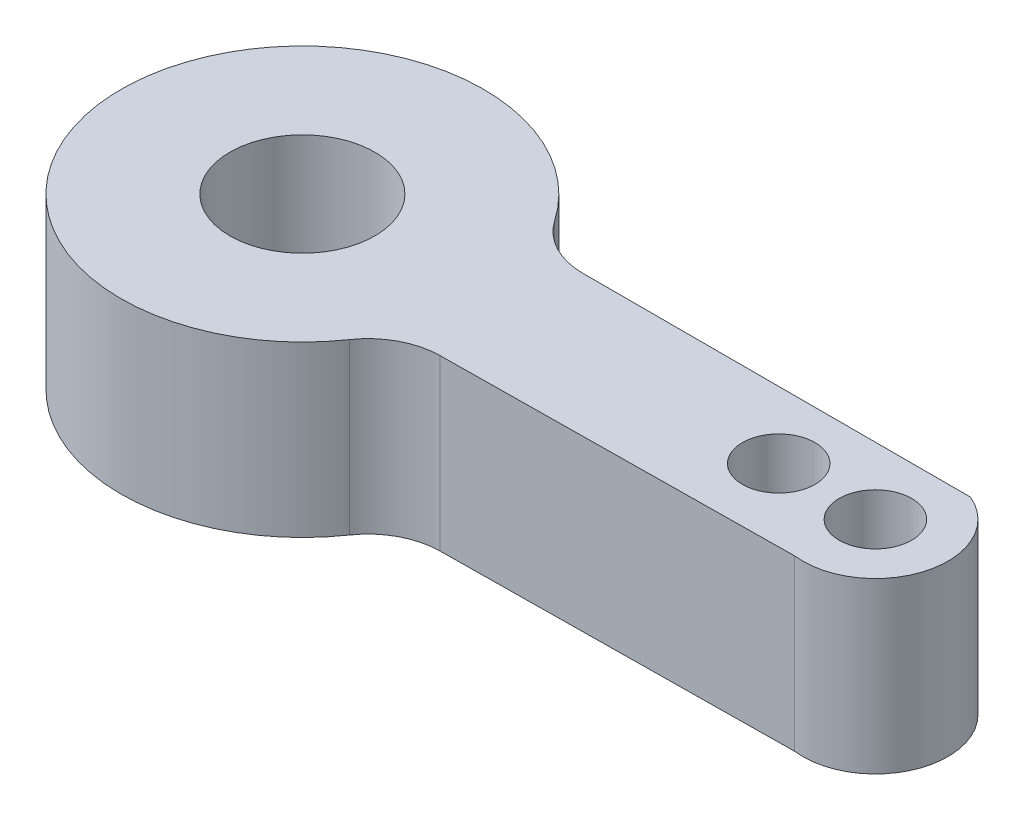
from build123d import *

# Parameters (mm, degrees)
SKETCH4_R           = 1.5
SKETCH4_R_2         = 3
BOSS_EXTRUDE1_DEPTH = 7
FILLET1_R           = 3


with BuildPart() as part:
    # Sketch4 → Boss-Extrude1 (new body)
    with BuildSketch(Plane(origin=(0, 0, 0), x_dir=(1, 0, 0), z_dir=(0, 1, 0))):
        with BuildLine():
            Line((6.89102232, 2.960373522), (24.66941446, 2.960373522))
            ThreePointArc((24.66941446, 2.960373522), (26.39916632, -0.573574214), (23.142085355, -2.780891971))
            Line((23.142085355, -2.780891971), (6.89102232, -2.960373522))
            ThreePointArc((6.89102232, -2.960373522), (4.125966468, -6.263098331), (0, -7.5))
            ThreePointArc((0, -7.5), (-7.5, 0), (0, 7.5))
            ThreePointArc((0, 7.5), (4.125966468, 6.263098331), (6.89102232, 2.960373522))
        make_face()
        with Locations((23.5, 0.197681027)):
            Circle(SKETCH4_R, mode=Mode.SUBTRACT)
        with Locations((19.5, 0.197681027)):
            Circle(SKETCH4_R, mode=Mode.SUBTRACT)
        Circle(SKETCH4_R_2, mode=Mode.SUBTRACT)
    extrude(amount=BOSS_EXTRUDE1_DEPTH)

    # Fillet1
    fillet1_edges = [part.edges().sort_by_distance(p)[0] for p in [
        (6.89102232, 3.5, -2.960373522),
        (6.89102232, 3.5, 2.960373522),
    ]]
    fillet(fillet1_edges, radius=FILLET1_R)


solid = part.part
